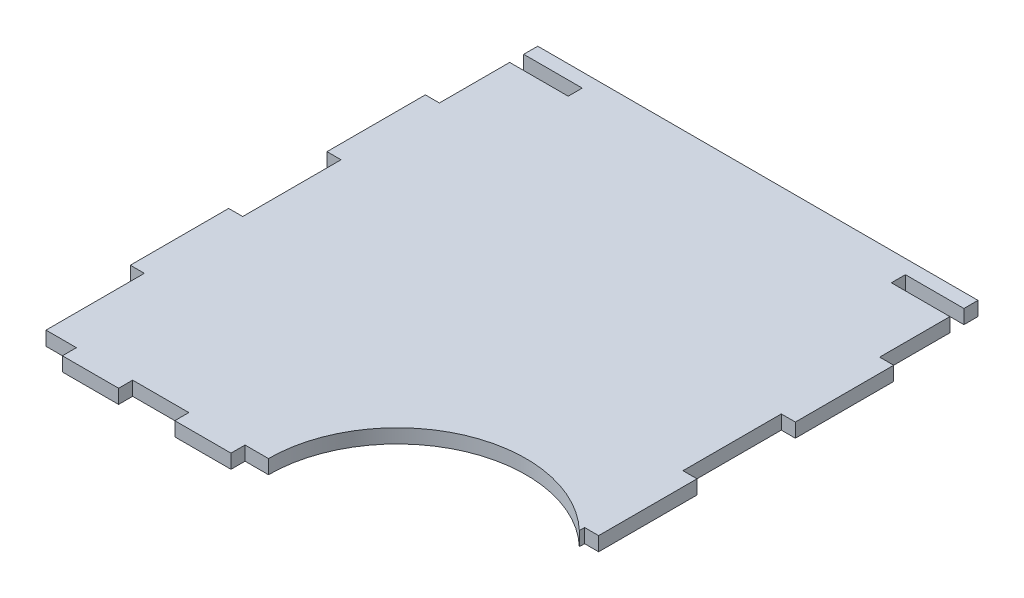
from build123d import *

# Parameters (mm, degrees)
BOSS_EXTRUDE1_DEPTH = 6


with BuildPart() as part:
    # Sketch1 → Boss-Extrude1 (new body)
    with BuildSketch(Plane(origin=(0, 0, 0), x_dir=(1, 0, 0), z_dir=(0, 1, 0))):
        with BuildLine():
            Line((-43.714285714, -124.928571429), (-43.714285714, -118.928571429))
            Line((-43.714285714, -118.928571429), (-67.714285714, -118.928571429))
            Line((-67.714285714, -118.928571429), (-67.714285714, -124.928571429))
            Line((-67.714285714, -124.928571429), (-91.714285714, -124.928571429))
            Line((-91.714285714, -124.928571429), (-91.714285714, -118.928571429))
            Line((-91.714285714, -118.928571429), (-104.714285714, -118.928571429))
            Line((-104.714285714, -118.928571429), (-104.714285714, -76.928571429))
            Line((-104.714285714, -76.928571429), (-110.714285714, -76.928571429))
            Line((-110.714285714, -76.928571429), (-110.714285714, -34.928571429))
            Line((-110.714285714, -34.928571429), (-104.714285714, -34.928571429))
            Line((-104.714285714, -34.928571429), (-104.714285714, 7.071428571))
            Line((-104.714285714, 7.071428571), (-110.714285714, 7.071428571))
            Line((-110.714285714, 7.071428571), (-110.714285714, 49.071428571))
            Line((-110.714285714, 49.071428571), (-104.714285714, 49.071428571))
            Line((-104.714285714, 49.071428571), (-104.714285714, 79.071428571))
            Line((-104.714285714, 79.071428571), (-79.714285714, 79.071428571))
            Line((-79.714285714, 79.071428571), (-79.714285714, 85.071428571))
            Line((-79.714285714, 85.071428571), (-104.714285714, 85.071428571))
            Line((-104.714285714, 85.071428571), (-104.714285714, 91.071428571))
            Line((-104.714285714, 91.071428571), (83.285714286, 91.071428571))
            Line((83.285714286, 91.071428571), (83.285714286, 85.071428571))
            Line((83.285714286, 85.071428571), (58.285714286, 85.071428571))
            Line((58.285714286, 85.071428571), (58.285714286, 79.071428571))
            Line((58.285714286, 79.071428571), (83.285714286, 79.071428571))
            Line((83.285714286, 79.071428571), (83.285714286, 49.071428571))
            Line((83.285714286, 49.071428571), (89.285714286, 49.071428571))
            Line((89.285714286, 49.071428571), (89.285714286, 7.071428571))
            Line((89.285714286, 7.071428571), (83.285714286, 7.071428571))
            Line((83.285714286, 7.071428571), (83.285714286, -34.928571429))
            Line((83.285714286, -34.928571429), (89.285714286, -34.928571429))
            Line((89.285714286, -34.928571429), (89.285714286, -76.928571429))
            Line((89.285714286, -76.928571429), (83.285714286, -76.928571429))
            Line((83.285714286, -76.928571429), (83.285714286, -79.166780724))
            ThreePointArc((83.285714286, -79.166780724), (23.663965975, -68.356840195), (-9.714285714, -118.928571429))
            Line((-9.714285714, -118.928571429), (-19.714285714, -118.928571429))
            Line((-19.714285714, -118.928571429), (-19.714285714, -124.928571429))
            Line((-19.714285714, -124.928571429), (-43.714285714, -124.928571429))
        make_face()
    extrude(amount=BOSS_EXTRUDE1_DEPTH)


solid = part.part
